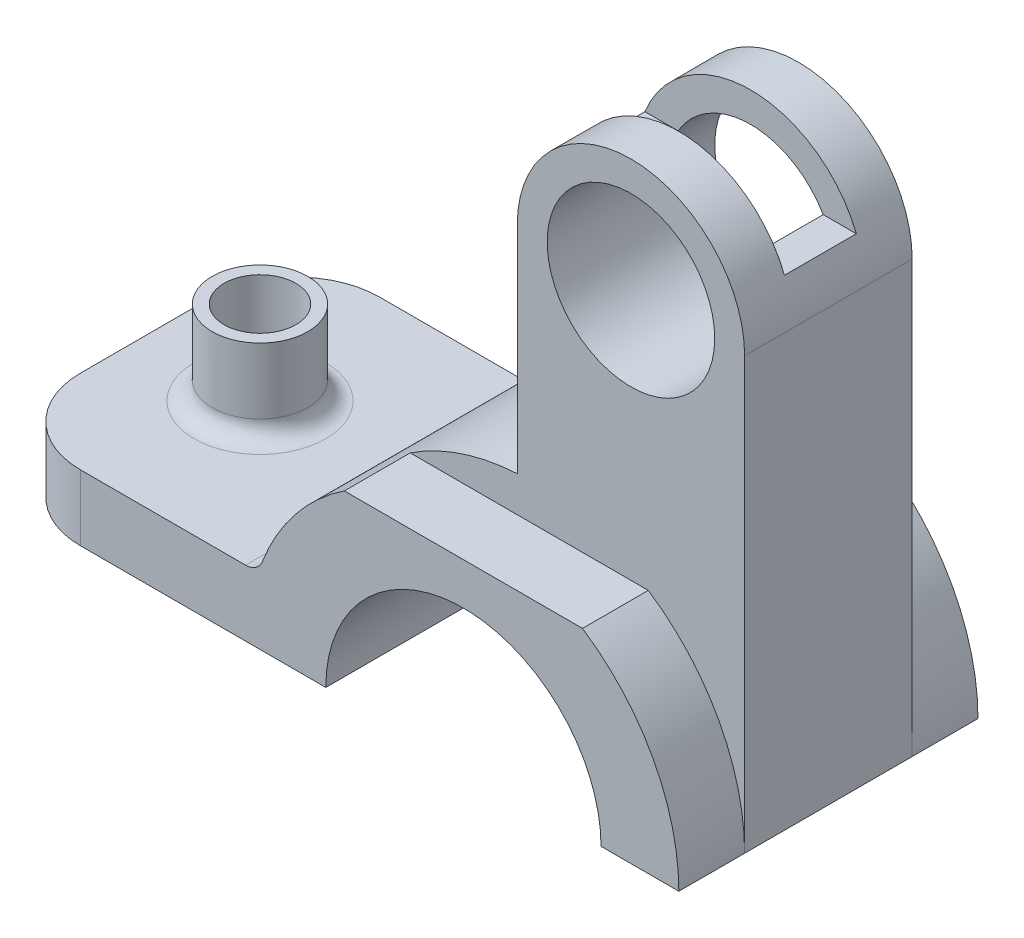
from build123d import *

# Parameters (mm, degrees)
BOSS_EXTRUDE3_DEPTH = 25
BOSS_EXTRUDE4_DEPTH = 14
SKETCH9_R           = 14
CUT_EXTRUDE5_DEPTH  = 97
SKETCH10_W          = 12
SKETCH10_H          = 12
CUT_EXTRUDE6_DEPTH  = 97
SKETCH11_R          = 8
BOSS_EXTRUDE5_DEPTH = 14
FILLET3_R           = 14
SKETCH12_R          = 6
CUT_EXTRUDE8_DEPTH  = 54
FILLET4_R           = 3


with BuildPart() as part:
    # Sketch2 → Boss-Extrude3 (new body, symmetric)
    with BuildSketch(Plane.XY):
        with BuildLine():
            Line((0, 0), (55, 0))
            ThreePointArc((55, 0), (78, 23), (101, 0))
            Line((101, 0), (114, 0))
            ThreePointArc((114, 0), (109.720584442, 17.023645986), (97.899748742, 30))
            Line((97.899748742, 30), (58.100251258, 30))
            ThreePointArc((58.100251258, 30), (49.293476177, 21.724076274), (43.721726998, 11))
            Line((43.721726998, 11), (0, 11))
            Line((0, 11), (0, 0))
        make_face()
    extrude(amount=BOSS_EXTRUDE3_DEPTH, both=True)

    # Sketch7 → Boss-Extrude4 (add, symmetric)
    with BuildSketch(Plane.XY):
        with BuildLine():
            Line((114, 0), (114, 72))
            ThreePointArc((114, 72), (95, 91), (76, 72))
            Line((76, 72), (76, 35.944401511))
            ThreePointArc((76, 35.944401511), (66.65391142, 34.165278777), (58.100251258, 30))
            Line((58.100251258, 30), (97.899748742, 30))
            ThreePointArc((97.899748742, 30), (109.720584442, 17.023645986), (114, 0))
        make_face()
    extrude(amount=BOSS_EXTRUDE4_DEPTH, both=True)

    # Sketch9 → Cut-Extrude5 (cut)
    with BuildSketch(Plane.XY.offset(14)):
        with Locations((95, 72)):
            Circle(SKETCH9_R)
    extrude(amount=-CUT_EXTRUDE5_DEPTH, mode=Mode.SUBTRACT)

    # Sketch10 → Cut-Extrude6 (cut)
    with BuildSketch(Plane(origin=(114, 0, 0), x_dir=(0, 0, -1), z_dir=(1, 0, 0))):
        with Locations((0, 85)):
            Rectangle(SKETCH10_W, SKETCH10_H)
    extrude(amount=-CUT_EXTRUDE6_DEPTH, mode=Mode.SUBTRACT)

    # Sketch11 → Boss-Extrude5 (add)
    with BuildSketch(Plane(origin=(0, 11, 0), x_dir=(1, 0, 0), z_dir=(0, 1, 0))):
        with Locations((19, 0)):
            Circle(SKETCH11_R)
    extrude(amount=BOSS_EXTRUDE5_DEPTH)

    # Fillet3
    fillet3_edges = [part.edges().sort_by_distance(p)[0] for p in [
        (0, 5.5, -25),
        (0, 5.5, 25),
    ]]
    fillet(fillet3_edges, radius=FILLET3_R)

    # Sketch12 → Cut-Extrude8 (cut)
    with BuildSketch(Plane(origin=(0, 25, 0), x_dir=(1, 0, 0), z_dir=(0, 1, 0))):
        with Locations((19, 0)):
            Circle(SKETCH12_R)
    extrude(amount=-CUT_EXTRUDE8_DEPTH, mode=Mode.SUBTRACT)

    # Fillet4
    fillet4_edges = [part.edges().sort_by_distance(p)[0] for p in [
        (43.721726998, 11, 0),
        (11, 11, 0),
    ]]
    fillet(fillet4_edges, radius=FILLET4_R)


solid = part.part
